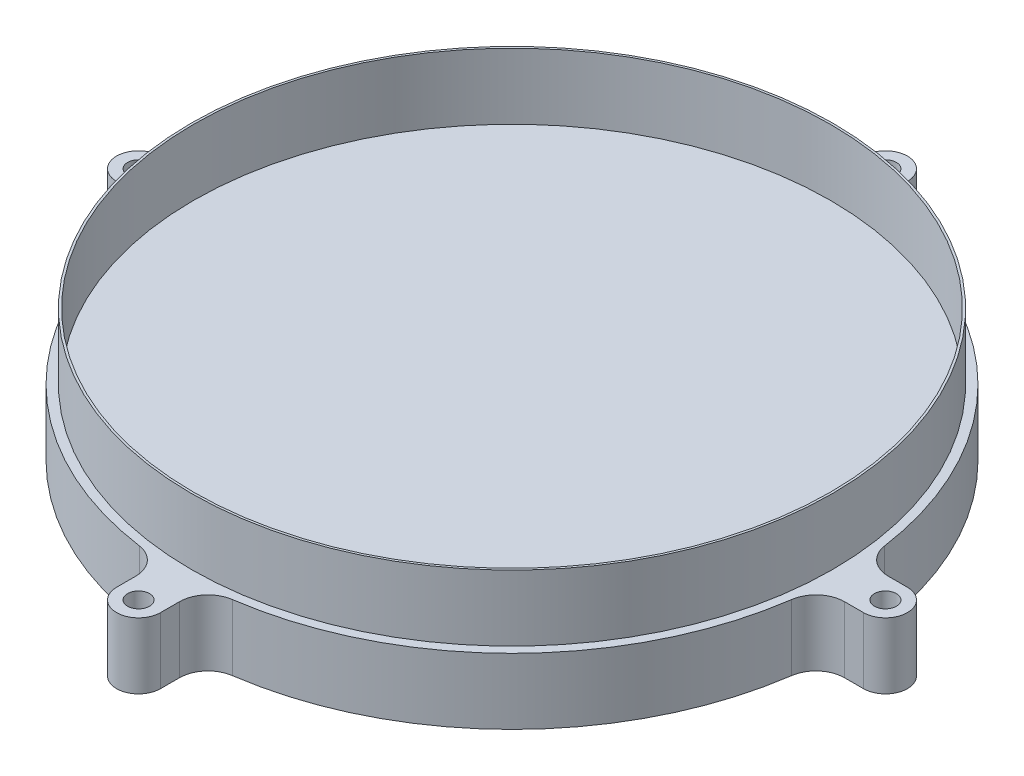
from build123d import *

# Parameters (mm, degrees)
SKETCH2_R           = 146
SKETCH2_R_2         = 145
BOSS_EXTRUDE2_DEPTH = 30
SKETCH3_R           = 5
BOSS_EXTRUDE4_DEPTH = 30


with BuildPart() as part:
    # Sketch2 → Boss-Extrude2 (new body)
    with BuildSketch(Plane(origin=(0, 0, 0), x_dir=(1, 0, 0), z_dir=(0, 1, 0))):
        Circle(SKETCH2_R)
        Circle(SKETCH2_R_2, mode=Mode.SUBTRACT)
    extrude(amount=BOSS_EXTRUDE2_DEPTH)

    # Sketch3 → Boss-Extrude4 (add)
    with BuildSketch(Plane(origin=(0, 0, 0), x_dir=(1, 0, 0), z_dir=(0, 1, 0))):
        with BuildLine():
            Line((161.369142032, 10), (170, 10))
            ThreePointArc((170, 10), (180, 0), (170, -10))
            Line((170, -10), (161.369142032, -10))
            ThreePointArc((161.369142032, -10), (152.849946816, -13.180462695), (148.499210458, -21.165644172))
            ThreePointArc((148.499210458, -21.165644172), (106.066017178, -106.066017178), (21.165644172, -148.499210458))
            ThreePointArc((21.165644172, -148.499210458), (13.180462695, -152.849946816), (10, -161.369142032))
            Line((10, -161.369142032), (10, -170))
            ThreePointArc((10, -170), (0, -180), (-10, -170))
            Line((-10, -170), (-10, -161.369142032))
            ThreePointArc((-10, -161.369142032), (-13.180462695, -152.849946816), (-21.165644172, -148.499210458))
            ThreePointArc((-21.165644172, -148.499210458), (-106.066017178, -106.066017178), (-148.499210458, -21.165644172))
            ThreePointArc((-148.499210458, -21.165644172), (-152.849946816, -13.180462695), (-161.369142032, -10))
            Line((-161.369142032, -10), (-170, -10))
            ThreePointArc((-170, -10), (-180, 0), (-170, 10))
            Line((-170, 10), (-161.369142032, 10))
            ThreePointArc((-161.369142032, 10), (-152.849946816, 13.180462695), (-148.499210458, 21.165644172))
            ThreePointArc((-148.499210458, 21.165644172), (-106.066017178, 106.066017178), (-21.165644172, 148.499210458))
            ThreePointArc((-21.165644172, 148.499210458), (-13.180462695, 152.849946816), (-10, 161.369142032))
            Line((-10, 161.369142032), (-10, 170))
            ThreePointArc((-10, 170), (0, 180), (10, 170))
            Line((10, 170), (10, 161.369142032))
            ThreePointArc((10, 161.369142032), (13.180462695, 152.849946816), (21.165644172, 148.499210458))
            ThreePointArc((21.165644172, 148.499210458), (106.066017178, 106.066017178), (148.499210458, 21.165644172))
            ThreePointArc((148.499210458, 21.165644172), (152.849946816, 13.180462695), (161.369142032, 10))
        make_face()
        with Locations((0, 170)):
            Circle(SKETCH3_R, mode=Mode.SUBTRACT)
        with Locations((170, 0)):
            Circle(SKETCH3_R, mode=Mode.SUBTRACT)
        with Locations((0, -170)):
            Circle(SKETCH3_R, mode=Mode.SUBTRACT)
        with Locations((-170, 0)):
            Circle(SKETCH3_R, mode=Mode.SUBTRACT)
    extrude(amount=-BOSS_EXTRUDE4_DEPTH)


solid = part.part
